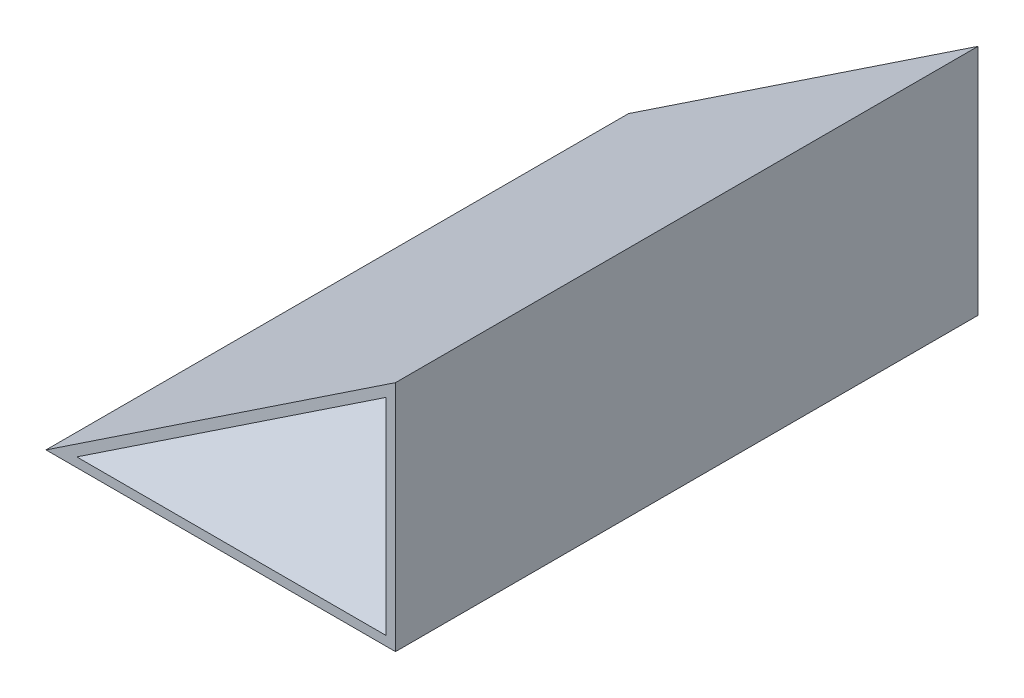
from build123d import *

# Parameters (mm, degrees)
EXTRUDE_1_DEPTH     = 250
CUT_EXTRUDE_1_DEPTH = 251


with BuildPart() as part:
    # 草图1 → 凸台-拉伸1 (new body)
    with BuildSketch(Plane.XY):
        Polygon((-104.641350211, -31.856540084), (45.358649789, -31.856540084), (45.358649789, 68.143459916), align=None)
    extrude(amount=EXTRUDE_1_DEPTH)

    # 草图2 → 切除-拉伸1 (cut, through all)
    with BuildSketch(Plane.XY.offset(250)):
        Polygon((41.358649789, 60.669391548), (41.358649789, -27.856540084), (-91.43024766, -27.856540084), align=None)
    extrude(amount=-CUT_EXTRUDE_1_DEPTH, mode=Mode.SUBTRACT)


solid = part.part
